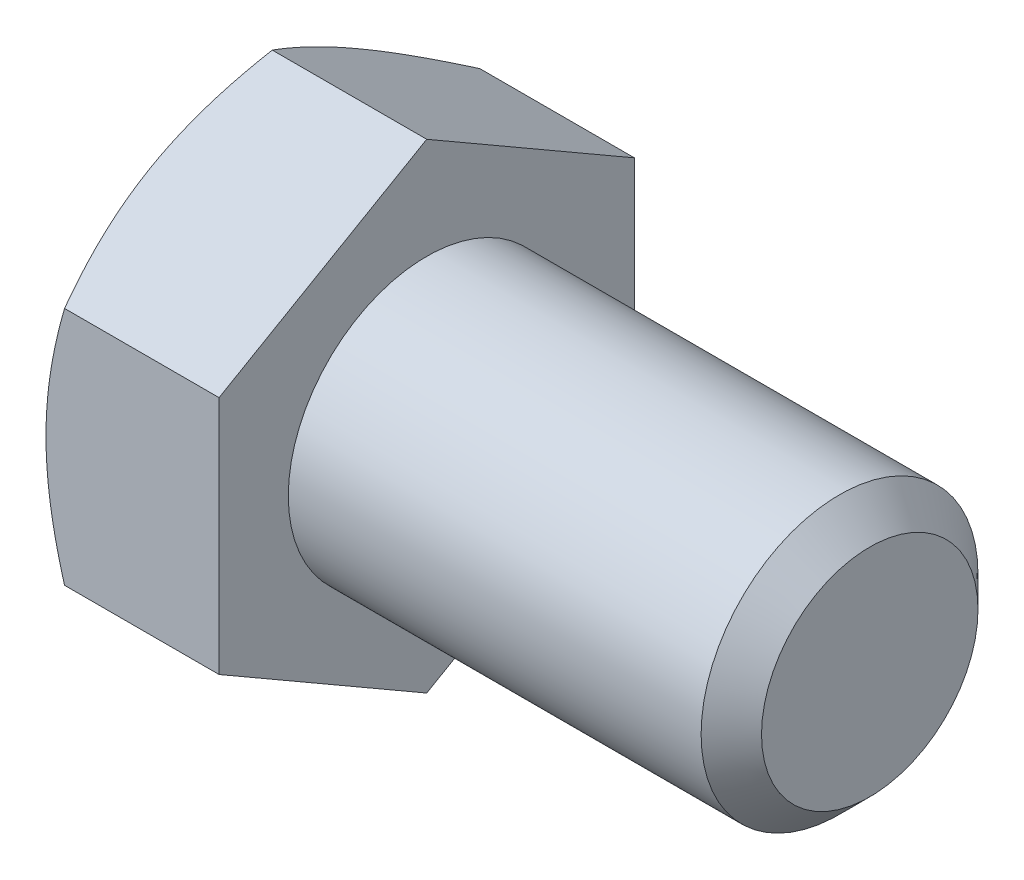
from build123d import *

# Parameters (mm, degrees)
SKETCH5_R           = 7.9375
BOSS_EXTRUDE3_DEPTH = 25.4
CHAMFER1_SIZE       = 1.731818182
BOSS_EXTRUDE4_DEPTH = 9.921875
SKETCH8_OUTSIDE_W   = 161.776
SKETCH8_OUTSIDE_H   = 165.46
SKETCH8_OUTSIDE_R   = 11.90625
CUT_EXTRUDE3_DEPTH  = 36.321875
CUT_EXTRUDE3_TAPER  = 60


with BuildPart() as part:
    # Sketch5 → Boss-Extrude3 (new body)
    with BuildSketch(Plane(origin=(17.6609375, 0, 0), x_dir=(0, 0, -1), z_dir=(1, 0, 0))):
        Circle(SKETCH5_R)
    extrude(amount=-BOSS_EXTRUDE3_DEPTH)

    # Chamfer1
    chamfer1_edges = [part.edges().sort_by_distance(p)[0] for p in [
        (17.6609375, 0, 7.9375),
    ]]
    chamfer(chamfer1_edges, length=CHAMFER1_SIZE)

    # Sketch6 → Boss-Extrude4 (add)
    with BuildSketch(Plane.ZY.offset(7.7390625)):
        Polygon((11.90625, 6.874076643), (0, 13.748153285), (-11.90625, 6.874076643), (-11.90625, -6.874076643), (0, -13.748153285), (11.90625, -6.874076643), align=None)
    extrude(amount=BOSS_EXTRUDE4_DEPTH)

    # Sketch8 outside → Cut-Extrude3 (cut, through all)
    with BuildSketch(Plane.ZY.offset(17.6609375)):
        Rectangle(SKETCH8_OUTSIDE_W, SKETCH8_OUTSIDE_H)
        Circle(SKETCH8_OUTSIDE_R, mode=Mode.SUBTRACT)
    extrude(amount=-CUT_EXTRUDE3_DEPTH, taper=CUT_EXTRUDE3_TAPER, mode=Mode.SUBTRACT)


solid = part.part
